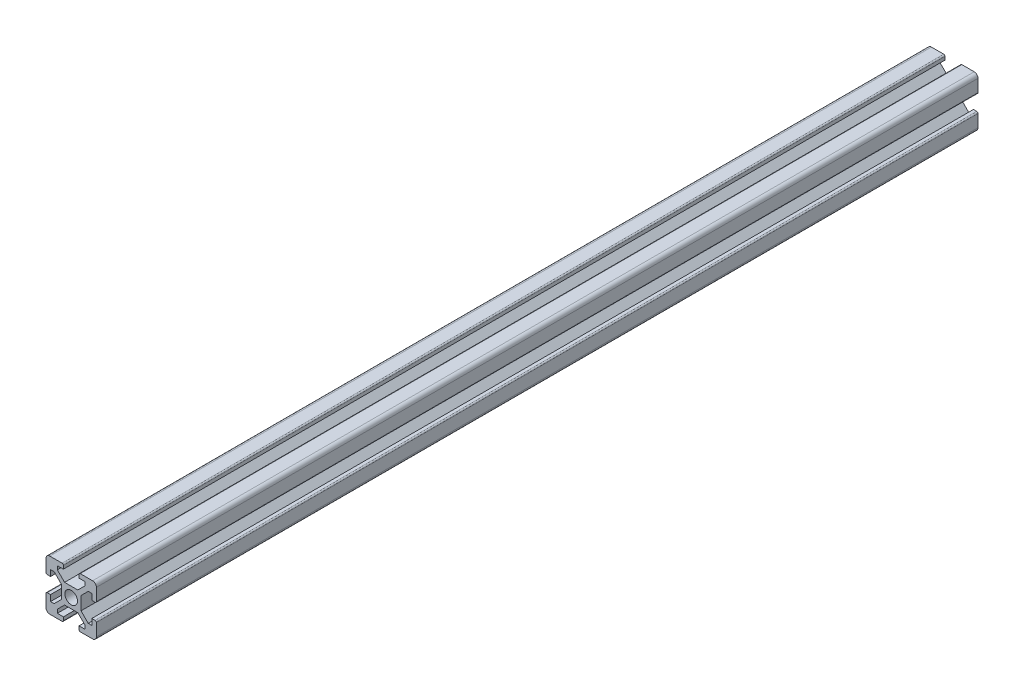
from build123d import *

# Parameters (mm, degrees)
SKETCH_1_R      = 2.5
EXTRUDE_1_DEPTH = 350
FILLET_1_R      = 1.5
FILLET_2_R      = 1.5
FILLET_3_R      = 1.5
FILLET_4_R      = 1.5
FILLET_5_R      = 0.5
FILLET_6_R      = 0.5
FILLET_7_R      = 0.5
FILLET_8_R      = 0.5
FILLET_9_R      = 0.5
FILLET_10_R     = 0.5
FILLET_11_R     = 0.5
FILLET_12_R     = 0.5


with BuildPart() as part:
    # 草图1 → 凸台-拉伸1 (new body)
    with BuildSketch(Plane.XY):
        Polygon((0, 6.9), (0, 0), (6.9, 0), (6.9, 1.8), (4.5, 1.8), (4.5, 3.227207794), (7.372792206, 6.1), (12.627207794, 6.1), (15.5, 3.227207794), (15.5, 1.8), (13.1, 1.8), (13.1, 0), (20, 0), (20, 6.9), (18.2, 6.9), (18.2, 4.5), (16.772792206, 4.5), (13.9, 7.372792206), (13.9, 12.627207794), (16.772792206, 15.5), (18.2, 15.5), (18.2, 13.1), (20, 13.1), (20, 20), (13.1, 20), (13.1, 18.2), (15.5, 18.2), (15.5, 16.772792206), (12.627207794, 13.9), (7.372792206, 13.9), (4.5, 16.772792206), (4.5, 18.2), (6.9, 18.2), (6.9, 20), (0, 20), (0, 13.1), (1.8, 13.1), (1.8, 15.5), (3.227207794, 15.5), (6.1, 12.627207794), (6.1, 7.372792206), (3.227207794, 4.5), (1.8, 4.5), (1.8, 6.9), align=None)
        with Locations((10, 10)):
            Circle(SKETCH_1_R, mode=Mode.SUBTRACT)
    extrude(amount=EXTRUDE_1_DEPTH)

    # 圆角1
    fillet_1_edges = [part.edges().sort_by_distance(p)[0] for p in [
        (20, 20, 175),
    ]]
    fillet(fillet_1_edges, radius=FILLET_1_R)

    # 圆角2
    fillet_2_edges = [part.edges().sort_by_distance(p)[0] for p in [
        (0, 20, 175),
    ]]
    fillet(fillet_2_edges, radius=FILLET_2_R)

    # 圆角3
    fillet_3_edges = [part.edges().sort_by_distance(p)[0] for p in [
        (0, 0, 175),
    ]]
    fillet(fillet_3_edges, radius=FILLET_3_R)

    # 圆角4
    fillet_4_edges = [part.edges().sort_by_distance(p)[0] for p in [
        (20, 0, 175),
    ]]
    fillet(fillet_4_edges, radius=FILLET_4_R)

    # 圆角5
    fillet_5_edges = [part.edges().sort_by_distance(p)[0] for p in [
        (13.1, 20, 175),
    ]]
    fillet(fillet_5_edges, radius=FILLET_5_R)

    # 圆角6
    fillet_6_edges = [part.edges().sort_by_distance(p)[0] for p in [
        (6.9, 20, 175),
    ]]
    fillet(fillet_6_edges, radius=FILLET_6_R)

    # 圆角7
    fillet_7_edges = [part.edges().sort_by_distance(p)[0] for p in [
        (0, 13.1, 175),
    ]]
    fillet(fillet_7_edges, radius=FILLET_7_R)

    # 圆角8
    fillet_8_edges = [part.edges().sort_by_distance(p)[0] for p in [
        (0, 6.9, 175),
    ]]
    fillet(fillet_8_edges, radius=FILLET_8_R)

    # 圆角9
    fillet_9_edges = [part.edges().sort_by_distance(p)[0] for p in [
        (6.9, 0, 175),
    ]]
    fillet(fillet_9_edges, radius=FILLET_9_R)

    # 圆角10
    fillet_10_edges = [part.edges().sort_by_distance(p)[0] for p in [
        (13.1, 0, 175),
    ]]
    fillet(fillet_10_edges, radius=FILLET_10_R)

    # 圆角11
    fillet_11_edges = [part.edges().sort_by_distance(p)[0] for p in [
        (20, 13.1, 175),
    ]]
    fillet(fillet_11_edges, radius=FILLET_11_R)

    # 圆角12
    fillet_12_edges = [part.edges().sort_by_distance(p)[0] for p in [
        (20, 6.9, 175),
    ]]
    fillet(fillet_12_edges, radius=FILLET_12_R)


solid = part.part
